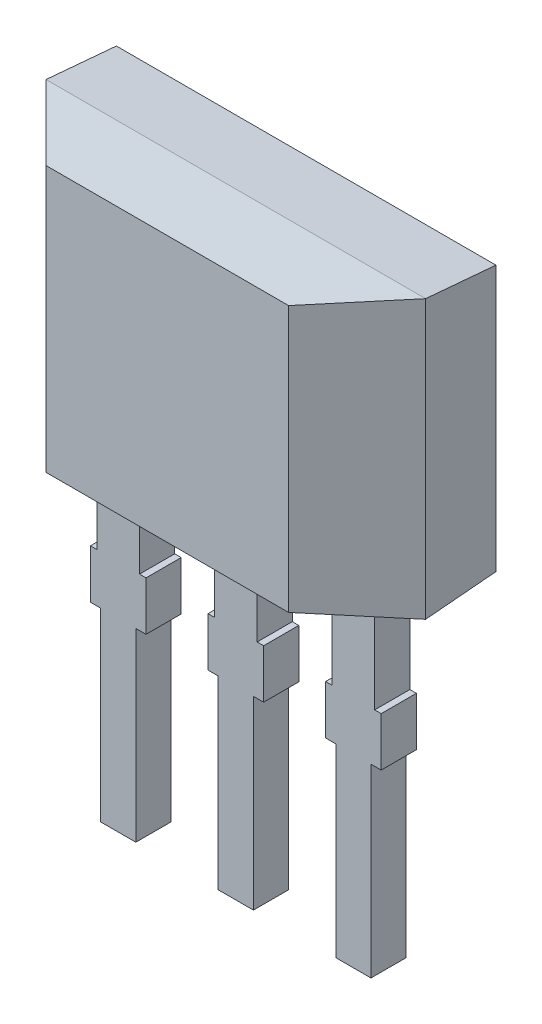
from build123d import *

# Parameters (mm, degrees)
SKETCH1_W                = 4.1
SKETCH1_H                = 3
EXTRUDE1_DEPTH           = 0.74
EXTRUDE1_TAPER           = 5
EXTRUDE1_OTHER_WAY_DEPTH = 0.76
CUT_EXTRUDE1_DEPTH       = 2.5
CUT_EXTRUDE1_DEPTH_BACK  = 2.5
CUT_EXTRUDE2_DEPTH       = 3.05
CUT_EXTRUDE2_DEPTH_BACK  = 3.05
EXTRUDE2_DEPTH           = 0.38


with BuildPart() as part:
    # Sketch1 → Extrude1 (new body)
    with BuildSketch(Plane.XY):
        Rectangle(SKETCH1_W, SKETCH1_H)
    extrude(amount=EXTRUDE1_DEPTH, taper=EXTRUDE1_TAPER)

    # Sketch1 → Extrude1 other way (add)
    with BuildSketch(Plane.XY):
        Rectangle(SKETCH1_W, SKETCH1_H)
    extrude(amount=-EXTRUDE1_OTHER_WAY_DEPTH)

    # Sketch2 → Cut-Extrude1 (cut, two sides)
    with BuildSketch(Plane(origin=(0, 0, 0), x_dir=(1, 0, 0), z_dir=(0, 1, 0))) as cut_extrude1_sk:
        Polygon((-2.05, 0), (-1.022969854, -1.027030146), (-2.05, -1.027030146), align=None)
        Polygon((2.05, 0), (1.060614086, -0.989385914), (2.05, -0.989385914), align=None)
    extrude(amount=CUT_EXTRUDE1_DEPTH, mode=Mode.SUBTRACT)
    extrude(cut_extrude1_sk.sketch, amount=-CUT_EXTRUDE1_DEPTH_BACK, mode=Mode.SUBTRACT)

    # Sketch3 → Cut-Extrude2 (cut, two sides)
    with BuildSketch(Plane(origin=(0, 0, 0), x_dir=(0, 0, -1), z_dir=(1, 0, 0))) as cut_extrude2_sk:
        Polygon((0, 1.5), (1.212386466, 1.393929928), (0.76, 1.5), align=None)
        Polygon((0, -1.5), (1.104320803, -1.5), (1.104320803, -1.403384449), align=None)
    extrude(amount=CUT_EXTRUDE2_DEPTH, mode=Mode.SUBTRACT)
    extrude(cut_extrude2_sk.sketch, amount=-CUT_EXTRUDE2_DEPTH_BACK, mode=Mode.SUBTRACT)

    # Sketch4 → Extrude2 (add)
    with BuildSketch(Plane.XY):
        Polygon((1.46, -3.15), (1.57, -3.15), (1.57, -2.62177976), (1.5, -2.62177976), (1.5, -0.78753646), (1.04, -0.78753646), (1.04, -2.62177976), (0.97, -2.62177976), (0.97, -3.15), (1.08, -3.15), (1.08, -5.15), (1.27, -5.15), (1.46, -5.15), align=None)
        Polygon((-1.08, -3.15), (-0.97, -3.15), (-0.97, -2.62177976), (-1.04, -2.62177976), (-1.04, -0.78753646), (-1.5, -0.78753646), (-1.5, -2.62177976), (-1.57, -2.62177976), (-1.57, -3.15), (-1.46, -3.15), (-1.46, -5.15), (-1.27, -5.15), (-1.08, -5.15), align=None)
        Polygon((0.23, -2.62177976), (0.3, -2.62177976), (0.3, -3.15), (0.19, -3.15), (0.19, -5.15), (0, -5.15), (-0.19, -5.15), (-0.19, -3.15), (-0.3, -3.15), (-0.3, -2.62177976), (-0.23, -2.62177976), (-0.23, -0.78753646), (0.23, -0.78753646), align=None)
    extrude(amount=-EXTRUDE2_DEPTH)


solid = part.part
